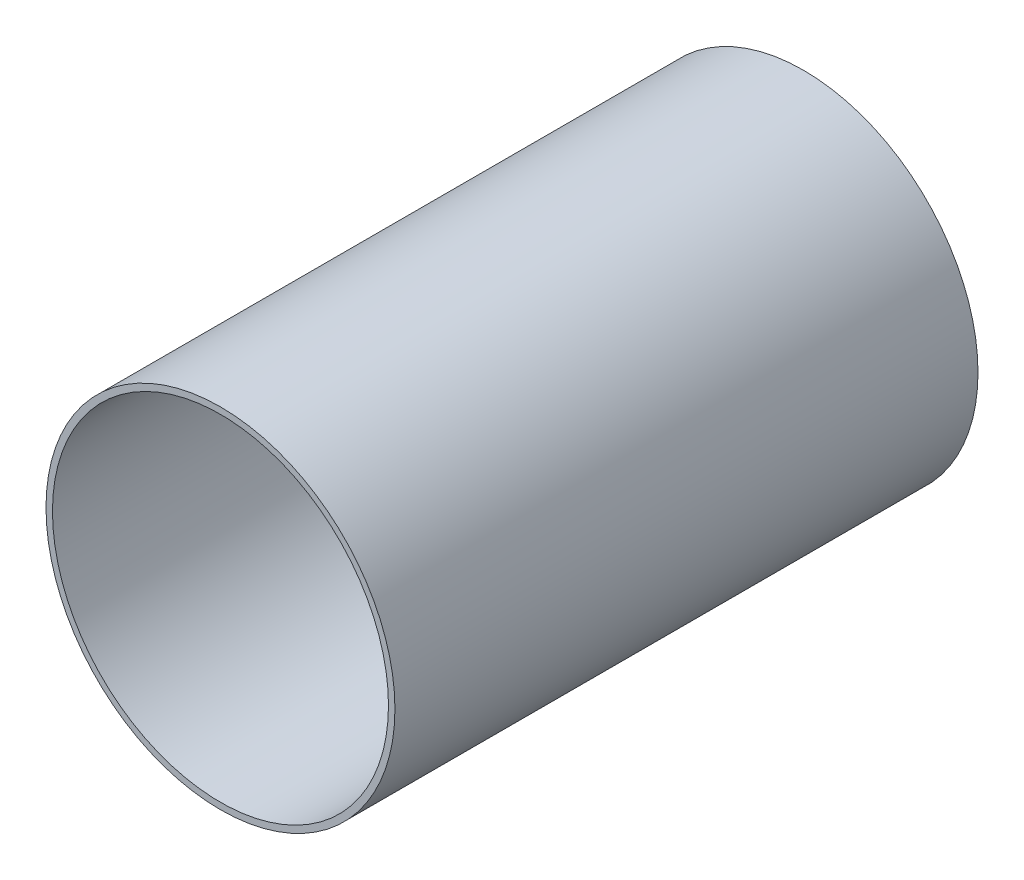
from build123d import *

# Parameters (mm, degrees)
SKETCH1_R           = 49.403
SKETCH1_R_2         = 47.5742
BOSS_EXTRUDE1_DEPTH = 165.1


with BuildPart() as part:
    # Sketch1 → Boss-Extrude1 (new body)
    with BuildSketch(Plane.XY):
        Circle(SKETCH1_R)
        Circle(SKETCH1_R_2, mode=Mode.SUBTRACT)
    extrude(amount=BOSS_EXTRUDE1_DEPTH)


solid = part.part
